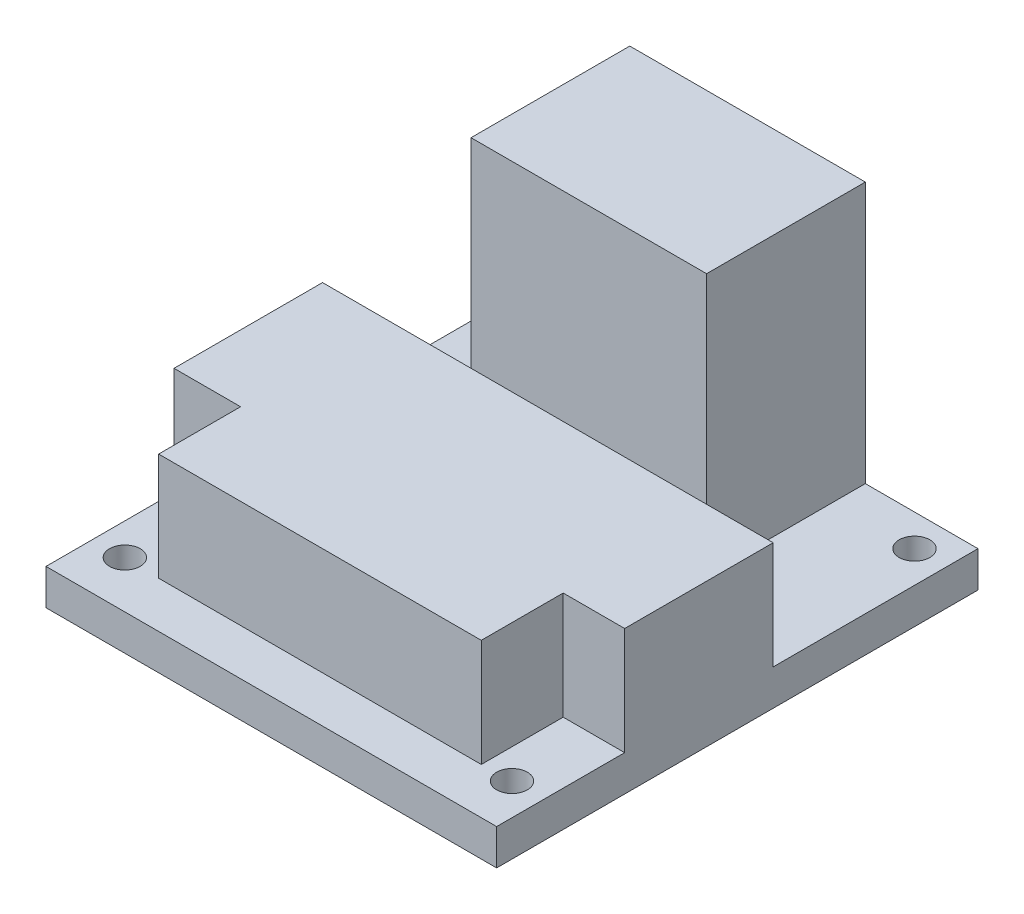
from build123d import *

# Parameters (mm, degrees)
SKETCH2_W               = 44
SKETCH2_H               = 47
BOSS_EXTRUDE1_DEPTH     = 3.5
SKETCH3_W               = 44
SKETCH3_H               = 22.5
BOSS_EXTRUDE2_DEPTH     = 10.5
SKETCH4_W               = 23
SKETCH4_H               = 15.5
BOSS_EXTRUDE3_DEPTH     = 25.5
SKETCH5_W               = 6.5
SKETCH5_H               = 8
SKETCH5_W_2             = 6
CUT_EXTRUDE1_DEPTH      = 10.5
SKETCH6_R               = 1.5
CUT_EXTRUDE3_DEPTH      = 30
CUT_EXTRUDE3_DEPTH_BACK = 1


with BuildPart() as part:
    # Sketch2 → Boss-Extrude1 (new body)
    with BuildSketch(Plane(origin=(0, 0, 0), x_dir=(1, 0, 0), z_dir=(0, 1, 0))):
        with Locations((22, 23.5)):
            Rectangle(SKETCH2_W, SKETCH2_H)
    extrude(amount=BOSS_EXTRUDE1_DEPTH)

    # Sketch3 → Boss-Extrude2 (add)
    with BuildSketch(Plane(origin=(0, 3.5, 0), x_dir=(1, 0, 0), z_dir=(0, 1, 0))):
        with Locations((22, 15.75)):
            Rectangle(SKETCH3_W, SKETCH3_H)
    extrude(amount=BOSS_EXTRUDE2_DEPTH)

    # Sketch4 → Boss-Extrude3 (add)
    with BuildSketch(Plane(origin=(0, 3.5, 0), x_dir=(1, 0, 0), z_dir=(0, 1, 0))):
        with Locations((21.5, 39.25)):
            Rectangle(SKETCH4_W, SKETCH4_H)
    extrude(amount=BOSS_EXTRUDE3_DEPTH)

    # Sketch5 → Cut-Extrude1 (cut)
    with BuildSketch(Plane(origin=(0, 14, 0), x_dir=(1, 0, 0), z_dir=(0, 1, 0))):
        with Locations((3.25, 8.5)):
            Rectangle(SKETCH5_W, SKETCH5_H)
        with Locations((41, 8.5)):
            Rectangle(SKETCH5_W_2, SKETCH5_H)
    extrude(amount=-CUT_EXTRUDE1_DEPTH, mode=Mode.SUBTRACT)

    # Sketch6 → Cut-Extrude3 (cut, two sides)
    with BuildSketch(Plane(origin=(0, 0, 0), x_dir=(1, 0, 0), z_dir=(0, 1, 0))) as cut_extrude3_sk:
        with Locations((3.1, 43.9)):
            Circle(SKETCH6_R)
        with Locations((40.9, 43.9)):
            Circle(SKETCH6_R)
        with Locations((40.9, 4.6)):
            Circle(SKETCH6_R)
        with Locations((3.1, 4.6)):
            Circle(SKETCH6_R)
    extrude(amount=CUT_EXTRUDE3_DEPTH, mode=Mode.SUBTRACT)
    extrude(cut_extrude3_sk.sketch, amount=-CUT_EXTRUDE3_DEPTH_BACK, mode=Mode.SUBTRACT)


solid = part.part
